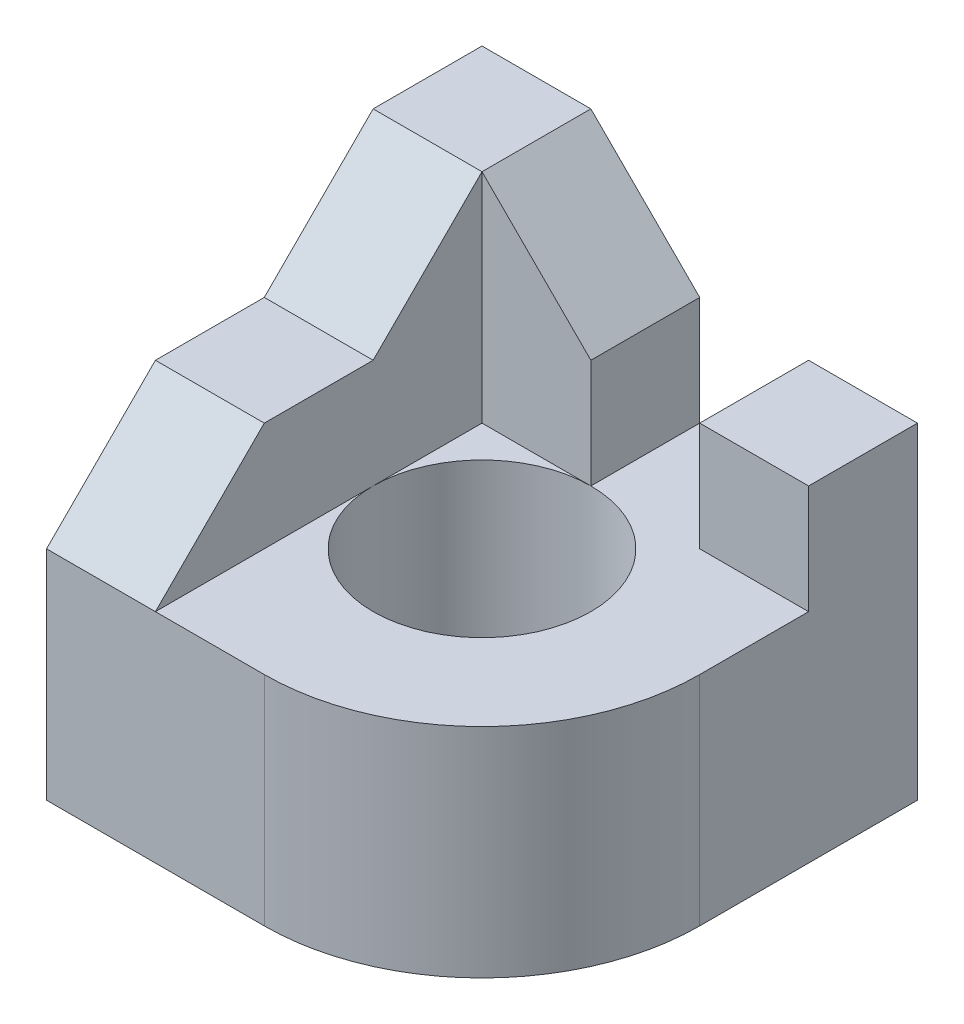
from build123d import *

# Parameters (mm, degrees)
SKETCH_1_W          = 40
SKETCH_1_H          = 40
EXTRUDE_1_DEPTH     = 40
SKETCH_2_R          = 10
CUT_EXTRUDE_1_DEPTH = 41
SKETCH_3_W          = 30
SKETCH_3_H          = 20
CUT_EXTRUDE_2_DEPTH = 20
CUT_EXTRUDE_3_DEPTH = 41
CUT_EXTRUDE_4_DEPTH = 41
SKETCH_7_W          = 10
SKETCH_7_H          = 10
CUT_EXTRUDE_5_DEPTH = 20
CUT_EXTRUDE_6_DEPTH = 21


with BuildPart() as part:
    # 草圖1 → 填料-伸長1 (new body)
    with BuildSketch(Plane(origin=(0, 0, 0), x_dir=(1, 0, 0), z_dir=(0, 1, 0))):
        Rectangle(SKETCH_1_W, SKETCH_1_H)
    extrude(amount=EXTRUDE_1_DEPTH)

    # 草圖2 → 除料-伸長1 (cut, through all)
    with BuildSketch(Plane(origin=(0, 40, 0), x_dir=(1, 0, 0), z_dir=(0, 1, 0))):
        Circle(SKETCH_2_R)
        with BuildLine():
            Line((0, -20), (20, -20))
            Line((20, -20), (20, 0))
            ThreePointArc((20, 0), (14.142135624, -14.142135624), (0, -20))
        make_face()
    extrude(amount=-CUT_EXTRUDE_1_DEPTH, mode=Mode.SUBTRACT)

    # 草圖3 → 除料-伸長2 (cut)
    with BuildSketch(Plane(origin=(20, 0, 0), x_dir=(0, 0, -1), z_dir=(1, 0, 0))):
        with Locations((-5, 30)):
            Rectangle(SKETCH_3_W, SKETCH_3_H)
    extrude(amount=-CUT_EXTRUDE_2_DEPTH, mode=Mode.SUBTRACT)

    # 草圖4 → 除料-伸長3 (cut, through all)
    with BuildSketch(Plane.XY.offset(20)):
        Polygon((20, 30), (10, 30), (10, 20), (0, 20), (0, 30), (-10, 40), (20, 40), align=None)
    extrude(amount=-CUT_EXTRUDE_3_DEPTH, mode=Mode.SUBTRACT)

    # 草圖5 → 除料-伸長4 (cut, through all)
    with BuildSketch(Plane(origin=(20, 0, 0), x_dir=(0, 0, -1), z_dir=(1, 0, 0))):
        Polygon((10, 40), (0, 30), (-10, 30), (-20, 20), (-20, 40), align=None)
    extrude(amount=-CUT_EXTRUDE_4_DEPTH, mode=Mode.SUBTRACT)

    # 草圖7 → 除料-伸長5 (cut)
    with BuildSketch(Plane.XY.offset(20)):
        with Locations((-5, 25)):
            Rectangle(SKETCH_7_W, SKETCH_7_H)
    extrude(amount=-CUT_EXTRUDE_5_DEPTH, mode=Mode.SUBTRACT)

    # 草圖9 → 除料-伸長6 (cut, through all)
    with BuildSketch(Plane(origin=(0, 20, 0), x_dir=(1, 0, 0), z_dir=(0, 1, 0))):
        with BuildLine():
            ThreePointArc((-7.071067812, 7.071067812), (-9.238795325, 3.826834324), (-10, 0))
            Line((-10, 0), (-10, 10))
            Line((-10, 10), (0, 10))
            ThreePointArc((0, 10), (-3.826834324, 9.238795325), (-7.071067812, 7.071067812))
        make_face()
    extrude(amount=CUT_EXTRUDE_6_DEPTH, mode=Mode.SUBTRACT)


solid = part.part
